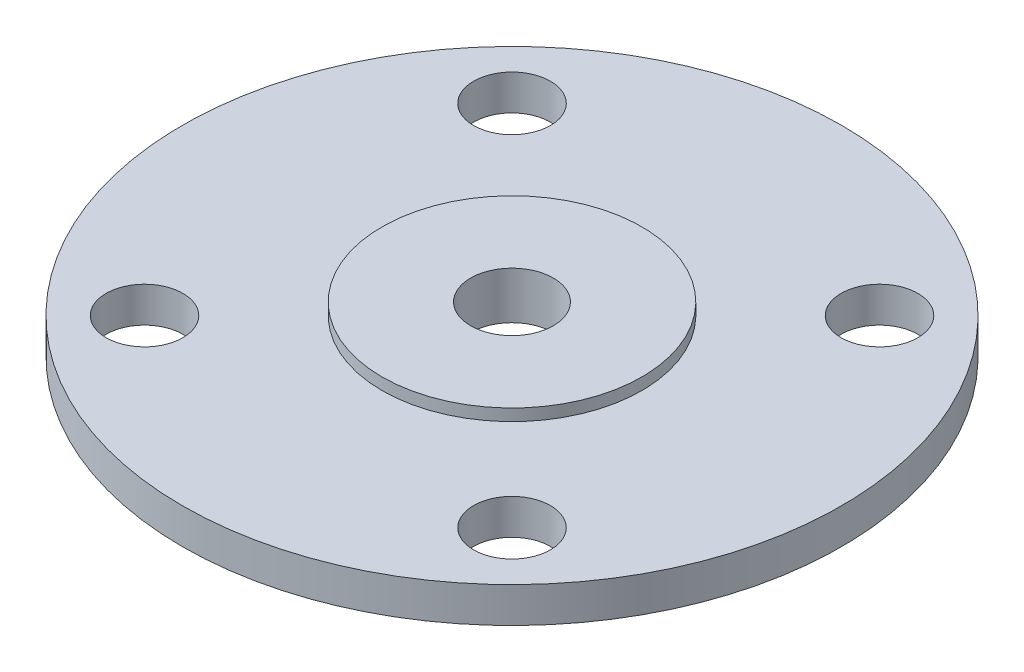
from build123d import *

# Parameters (mm, degrees)
SKETCH1_R           = 27.889608224
SKETCH1_R_2         = 3.5
SKETCH1_R_3         = 3.25
BOSS_EXTRUDE1_DEPTH = 3
BOSS_EXTRUDE2_START = 1
SKETCH1_5_R         = 11
SKETCH1_5_R_2       = 3.5
BOSS_EXTRUDE2_DEPTH = 1
BOSS_EXTRUDE3_DEPTH = 6
CHAMFER1_SIZE       = 4
SKETCH3_R           = 1.5
CUT_EXTRUDE1_DEPTH  = 6
CIRPATTERN1_COUNT   = 4


with BuildPart() as part:
    # Sketch1 → Boss-Extrude1 (new body)
    with BuildSketch(Plane(origin=(0, 0, 0), x_dir=(1, 0, 0), z_dir=(0, 1, 0))):
        Circle(SKETCH1_R)
        Circle(SKETCH1_R_2, mode=Mode.SUBTRACT)
        with Locations((-15.55, -15.55)):
            Circle(SKETCH1_R_3, mode=Mode.SUBTRACT)
        with Locations((15.55, -15.55)):
            Circle(SKETCH1_R_3, mode=Mode.SUBTRACT)
        with Locations((-15.55, 15.55)):
            Circle(SKETCH1_R_3, mode=Mode.SUBTRACT)
        with Locations((15.55, 15.55)):
            Circle(SKETCH1_R_3, mode=Mode.SUBTRACT)
    extrude(amount=-BOSS_EXTRUDE1_DEPTH)

    # Sketch1_5 → Boss-Extrude2 (add)
    with BuildSketch(Plane(origin=(0, 0, 0), x_dir=(1, 0, 0), z_dir=(0, 1, 0)).offset(BOSS_EXTRUDE2_START)):
        Circle(SKETCH1_5_R)
        Circle(SKETCH1_5_R_2, mode=Mode.SUBTRACT)
    extrude(amount=-BOSS_EXTRUDE2_DEPTH)

    # Sketch2 → Boss-Extrude3 (add)
    with BuildSketch(Plane.XZ.offset(3)):
        with BuildLine():
            Line((-19.607997757, -3), (-7.607997757, -3))
            ThreePointArc((-7.607997757, -3), (-8.178118969, 0), (-7.607997757, 3))
            Line((-7.607997757, 3), (-19.607997757, 3))
            Line((-19.607997757, 3), (-19.607997757, -3))
        make_face()
        with BuildLine():
            Line((-3, 19.607997757), (3, 19.607997757))
            Line((3, 19.607997757), (3, 7.607997757))
            ThreePointArc((3, 7.607997757), (0, 8.178118969), (-3, 7.607997757))
            Line((-3, 7.607997757), (-3, 19.607997757))
        make_face()
        with BuildLine():
            Line((19.607997757, -3), (7.607997757, -3))
            ThreePointArc((7.607997757, -3), (8.178118969, 0), (7.607997757, 3))
            Line((7.607997757, 3), (19.607997757, 3))
            Line((19.607997757, 3), (19.607997757, -3))
        make_face()
        with BuildLine():
            Line((-3, -19.607997757), (3, -19.607997757))
            Line((3, -19.607997757), (3, -7.607997757))
            ThreePointArc((3, -7.607997757), (0, -8.178118969), (-3, -7.607997757))
            Line((-3, -7.607997757), (-3, -19.607997757))
        make_face()
    extrude(amount=BOSS_EXTRUDE3_DEPTH)

    # Chamfer1
    chamfer1_edges = [part.edges().sort_by_distance(p)[0] for p in [
        (-8.178118969, -9, 0),
        (0, -9, 8.178118969),
        (8.178118969, -9, 0),
        (0, -9, -8.178118969),
    ]]
    chamfer(chamfer1_edges, length=CHAMFER1_SIZE)

    # Sketch3 → Cut-Extrude1 (cut)
    with BuildSketch(Plane.ZY.offset(19.607997757)):
        with Locations((0, -6)):
            Circle(SKETCH3_R)
    cut_extrude1 = extrude(amount=-CUT_EXTRUDE1_DEPTH, mode=Mode.SUBTRACT)

    # CirPattern1: Cut-Extrude1 ×4 about axis
    cirpattern1_axis = Axis((0, -3, 0), (0, 1, 0))
    for i in range(1, CIRPATTERN1_COUNT):
        add(cut_extrude1.rotate(cirpattern1_axis, i * 360 / CIRPATTERN1_COUNT), mode=Mode.SUBTRACT)


solid = part.part
